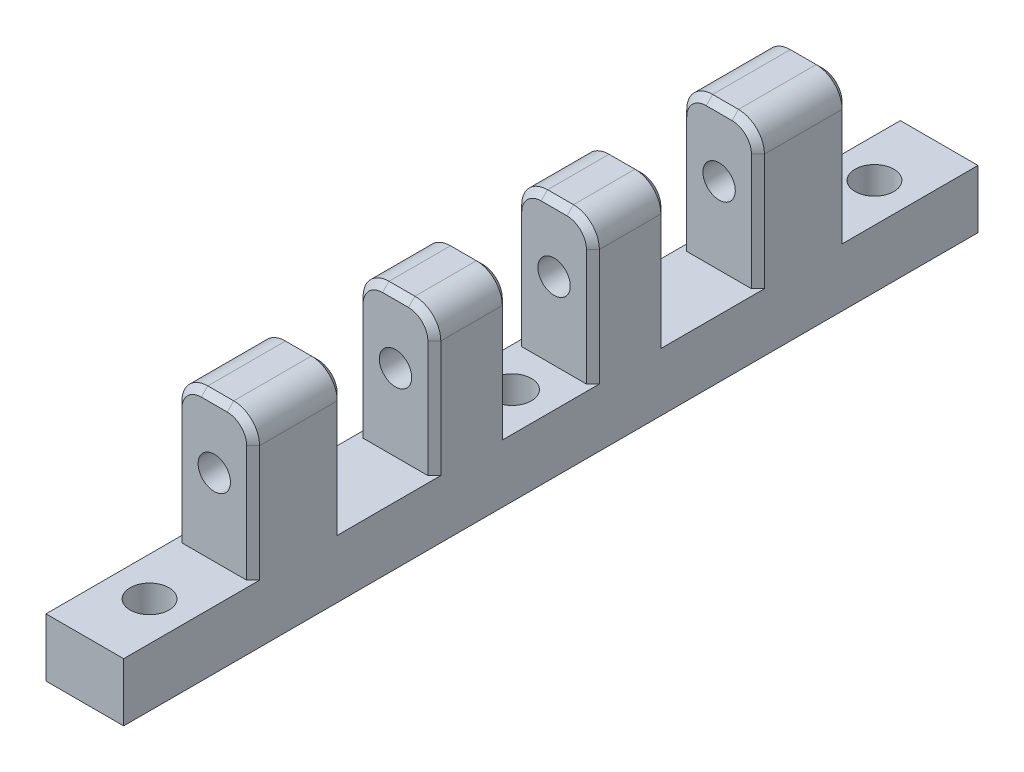
from build123d import *

# Parameters (mm, degrees)
SKETCH_1_W          = 66
SKETCH_1_H          = 4.5
EXTRUDE_1_DEPTH     = 6
SKETCH_2_W          = 5.75
SKETCH_2_H          = 11
SKETCH_2_W_2        = 7
EXTRUDE_2_DEPTH     = 6
SKETCH_3_R          = 1.25
CUT_EXTRUDE_1_DEPTH = 51
SKETCH_4_R          = 1.5
CUT_EXTRUDE_2_DEPTH = 51
FILLET_1_R          = 2
FILLET_2_R          = 2
FILLET_3_R          = 2
FILLET_4_R          = 2
FILLET_5_R          = 2
FILLET_6_R          = 2
FILLET_7_R          = 2
FILLET_8_R          = 2
CHAMFER_1_SIZE      = 0.5
CHAMFER_2_SIZE      = 0.5


with BuildPart() as part:
    # 草图1 → 凸台-拉伸1 (new body)
    with BuildSketch(Plane(origin=(0, 0, 0), x_dir=(0, 0, -1), z_dir=(1, 0, 0))):
        Rectangle(SKETCH_1_W, SKETCH_1_H)
    extrude(amount=EXTRUDE_1_DEPTH)

    # 草图2 → 凸台-拉伸2 (add)
    with BuildSketch(Plane.ZY):
        with Locations((6.125, 7.75)):
            Rectangle(SKETCH_2_W, SKETCH_2_H)
        with Locations((19.5, 7.75)):
            Rectangle(SKETCH_2_W_2, SKETCH_2_H)
        with Locations((-19.5, 7.75)):
            Rectangle(SKETCH_2_W_2, SKETCH_2_H)
        with Locations((-6.125, 7.75)):
            Rectangle(SKETCH_2_W, SKETCH_2_H)
    extrude(amount=-EXTRUDE_2_DEPTH)

    # 草图3 → 切除-拉伸1 (cut)
    with BuildSketch(Plane.XY.offset(23)):
        with Locations((3, 8.182)):
            Circle(SKETCH_3_R)
    extrude(amount=-CUT_EXTRUDE_1_DEPTH, mode=Mode.SUBTRACT)

    # 草图4 → 切除-拉伸2 (cut)
    with BuildSketch(Plane(origin=(0, 2.25, 0), x_dir=(1, 0, 0), z_dir=(0, 1, 0))):
        with Locations((3, 0)):
            Circle(SKETCH_4_R)
        with Locations((3, 28)):
            Circle(SKETCH_4_R)
        with Locations((3, -28)):
            Circle(SKETCH_4_R)
    extrude(amount=-CUT_EXTRUDE_2_DEPTH, mode=Mode.SUBTRACT)

    # 圆角1
    fillet_1_edges = [part.edges().sort_by_distance(p)[0] for p in [
        (6, 13.25, 19.5),
    ]]
    fillet(fillet_1_edges, radius=FILLET_1_R)

    # 圆角2
    fillet_2_edges = [part.edges().sort_by_distance(p)[0] for p in [
        (6, 13.25, -19.5),
    ]]
    fillet(fillet_2_edges, radius=FILLET_2_R)

    # 圆角3
    fillet_3_edges = [part.edges().sort_by_distance(p)[0] for p in [
        (6, 13.25, 6.125),
    ]]
    fillet(fillet_3_edges, radius=FILLET_3_R)

    # 圆角4
    fillet_4_edges = [part.edges().sort_by_distance(p)[0] for p in [
        (6, 13.25, -6.125),
    ]]
    fillet(fillet_4_edges, radius=FILLET_4_R)

    # 圆角5
    fillet_5_edges = [part.edges().sort_by_distance(p)[0] for p in [
        (0, 13.25, -19.5),
    ]]
    fillet(fillet_5_edges, radius=FILLET_5_R)

    # 圆角6
    fillet_6_edges = [part.edges().sort_by_distance(p)[0] for p in [
        (0, 13.25, -6.125),
    ]]
    fillet(fillet_6_edges, radius=FILLET_6_R)

    # 圆角7
    fillet_7_edges = [part.edges().sort_by_distance(p)[0] for p in [
        (0, 13.25, 6.125),
    ]]
    fillet(fillet_7_edges, radius=FILLET_7_R)

    # 圆角8
    fillet_8_edges = [part.edges().sort_by_distance(p)[0] for p in [
        (0, 13.25, 19.5),
    ]]
    fillet(fillet_8_edges, radius=FILLET_8_R)

    # 倒角1
    chamfer_1_edges = [part.edges().sort_by_distance(p)[0] for p in [
        (3, 13.25, -16),
        (5.414213562, 12.664213562, -16),
        (0.585786438, 12.664213562, -16),
        (6, 6.75, -16),
        (0, 6.75, -16),
    ]]
    chamfer(chamfer_1_edges, length=CHAMFER_1_SIZE)

    # 倒角2
    chamfer_2_edges = [part.edges().sort_by_distance(p)[0] for p in [
        (0, 6.75, -23),
        (6, 6.75, -23),
        (0.585786438, 12.664213562, -23),
        (5.414213562, 12.664213562, -23),
        (3, 13.25, -23),
        (0, 6.75, -9),
        (6, 6.75, -9),
        (0.585786438, 12.664213562, -9),
        (5.414213562, 12.664213562, -9),
        (3, 13.25, -9),
        (0, 6.75, 3.25),
        (6, 6.75, 3.25),
        (0.585786438, 12.664213562, 3.25),
        (5.414213562, 12.664213562, 3.25),
        (3, 13.25, 3.25),
        (0, 6.75, 16),
        (6, 6.75, 16),
        (0.585786438, 12.664213562, 16),
        (5.414213562, 12.664213562, 16),
        (3, 13.25, 16),
        (0, 6.75, 23),
        (6, 6.75, 23),
        (0.585786438, 12.664213562, 23),
        (5.414213562, 12.664213562, 23),
        (3, 13.25, 23),
        (0, 6.75, 9),
        (6, 6.75, 9),
        (0.585786438, 12.664213562, 9),
        (5.414213562, 12.664213562, 9),
        (3, 13.25, 9),
        (0, 6.75, -3.25),
        (6, 6.75, -3.25),
        (0.585786438, 12.664213562, -3.25),
        (5.414213562, 12.664213562, -3.25),
        (3, 13.25, -3.25),
    ]]
    chamfer(chamfer_2_edges, length=CHAMFER_2_SIZE)


solid = part.part
